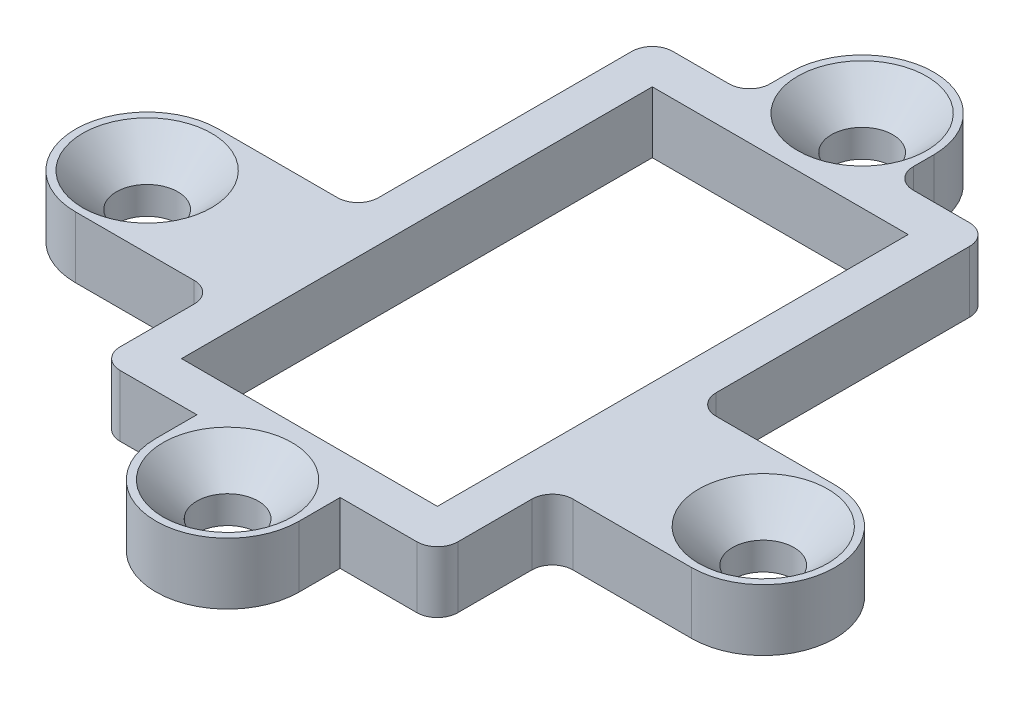
from build123d import *

# Parameters (mm, degrees)
SKETCH1_R                                      = 3.5
SKETCH1_W                                      = 16.5
SKETCH1_H                                      = 27
SKETCH1_W_2                                    = 12.5
SKETCH1_H_2                                    = 23
BOSS_EXTRUDE1_DEPTH                            = 3
FILLET1_R                                      = 1
CSK_FOR_M3_FLAT_HEAD_MACHINE_SCREW2_AT_2_COUNT = 2
CSK_FOR_M3_FLAT_HEAD_MACHINE_SCREW2_AT_2_PITCH = 30.1
CSK_FOR_M3_FLAT_HEAD_MACHINE_SCREW2_AT_3_COUNT = 2
CSK_FOR_M3_FLAT_HEAD_MACHINE_SCREW2_AT_3_PITCH = 18.712479793
CSK_FOR_M3_FLAT_HEAD_MACHINE_SCREW2_AT_4_COUNT = 2
CSK_FOR_M3_FLAT_HEAD_MACHINE_SCREW2_AT_4_PITCH = 24.934251543


with BuildPart() as part:
    # Sketch1 → Boss-Extrude1 (new body)
    with BuildSketch(Plane(origin=(0, 0, 0), x_dir=(1, 0, 0), z_dir=(0, 1, 0))):
        with BuildLine():
            ThreePointArc((-11.55, 0), (-12.575126266, 2.474873734), (-15.05, 3.5))
            ThreePointArc((-15.05, 3.5), (-18.55, 0), (-15.05, -3.5))
            ThreePointArc((-15.05, -3.5), (-12.575126266, -2.474873734), (-11.55, 0))
        make_face()
        with BuildLine():
            Line((-8.25, -3.5), (-8.25, 3.5))
            Line((-8.25, 3.5), (-15.05, 3.5))
            ThreePointArc((-15.05, 3.5), (-12.575126266, 2.474873734), (-11.55, 0))
            ThreePointArc((-11.55, 0), (-12.575126266, -2.474873734), (-15.05, -3.5))
            Line((-15.05, -3.5), (-8.25, -3.5))
        make_face()
        with Locations((0, -11.12)):
            Circle(SKETCH1_R)
        with Locations((0, 19.88)):
            Circle(SKETCH1_R)
        with Locations((0, 4.38)):
            Rectangle(SKETCH1_W, SKETCH1_H)
        with Locations((0, 4.38)):
            Rectangle(SKETCH1_W_2, SKETCH1_H_2, mode=Mode.SUBTRACT)
        with BuildLine():
            Line((-2.872281323, -9.12), (-3.5, -9.12))
            Line((-3.5, -9.12), (-3.5, -11.12))
            ThreePointArc((-3.5, -11.12), (-3.339385021, -10.071902827), (-2.872281323, -9.12))
        make_face()
        with BuildLine():
            ThreePointArc((2.872281323, -9.12), (0, -7.62), (-2.872281323, -9.12))
            Line((-2.872281323, -9.12), (2.872281323, -9.12))
        make_face()
        with BuildLine():
            Line((2.872281323, -9.12), (-2.872281323, -9.12))
            ThreePointArc((-2.872281323, -9.12), (-3.339385021, -10.071902827), (-3.5, -11.12))
            ThreePointArc((-3.5, -11.12), (0, -14.62), (3.5, -11.12))
            ThreePointArc((3.5, -11.12), (3.339385021, -10.071902827), (2.872281323, -9.12))
        make_face()
        with BuildLine():
            Line((3.5, -9.12), (2.872281323, -9.12))
            ThreePointArc((2.872281323, -9.12), (3.339385021, -10.071902827), (3.5, -11.12))
            Line((3.5, -11.12), (3.5, -9.12))
        make_face()
        with BuildLine():
            ThreePointArc((3.5, 19.88), (3.339385021, 18.831902827), (2.872281323, 17.88))
            Line((2.872281323, 17.88), (3.5, 17.88))
            Line((3.5, 17.88), (3.5, 19.88))
        make_face()
        with BuildLine():
            Line((2.872281323, 17.88), (-2.872281323, 17.88))
            ThreePointArc((-2.872281323, 17.88), (0, 16.38), (2.872281323, 17.88))
        make_face()
        with BuildLine():
            Line((-3.5, 19.88), (-3.5, 17.88))
            Line((-3.5, 17.88), (-2.872281323, 17.88))
            ThreePointArc((-2.872281323, 17.88), (-3.339385021, 18.831902827), (-3.5, 19.88))
        make_face()
        with BuildLine():
            ThreePointArc((-3.5, 19.88), (-3.339385021, 18.831902827), (-2.872281323, 17.88))
            Line((-2.872281323, 17.88), (2.872281323, 17.88))
            ThreePointArc((2.872281323, 17.88), (3.339385021, 18.831902827), (3.5, 19.88))
            ThreePointArc((3.5, 19.88), (0, 23.38), (-3.5, 19.88))
        make_face()
        with BuildLine():
            Line((15.05, 3.5), (8.25, 3.5))
            Line((8.25, 3.5), (8.25, -3.5))
            Line((8.25, -3.5), (15.05, -3.5))
            ThreePointArc((15.05, -3.5), (11.55, 0), (15.05, 3.5))
        make_face()
        with BuildLine():
            ThreePointArc((18.55, 0), (17.524873734, 2.474873734), (15.05, 3.5))
            ThreePointArc((15.05, 3.5), (11.55, 0), (15.05, -3.5))
            ThreePointArc((15.05, -3.5), (17.524873734, -2.474873734), (18.55, 0))
        make_face()
    extrude(amount=BOSS_EXTRUDE1_DEPTH)

    # Fillet1
    fillet1_edges = [part.edges().sort_by_distance(p)[0] for p in [
        (3.5, 1.5, -17.88),
        (8.25, 1.5, -17.88),
        (8.25, 1.5, -3.5),
        (8.25, 1.5, 3.5),
        (8.25, 1.5, 9.12),
        (-8.25, 1.5, 9.12),
        (-8.25, 1.5, 3.5),
        (-8.25, 1.5, -3.5),
        (-8.25, 1.5, -17.88),
        (-3.5, 1.5, -17.88),
    ]]
    fillet(fillet1_edges, radius=FILLET1_R)

    # Sketch2 → CSK for M3 Flat Head Machine Screw2 (revolve, cut)
    with BuildSketch(Plane(origin=(15.05, 3, 0), x_dir=(0, 0, 1), z_dir=(1, 0, 0))):
        Polygon((0, 0), (0, 3), (1.5, 3), (1.5, 1.65), (3.15, 0), align=None)
    csk_for_m3_flat_head_machine_screw2 = revolve(axis=Axis((15.05, 9.35, 0), (0, -1, 0)), mode=Mode.SUBTRACT)

    # CSK for M3 Flat Head Machine Screw2 at 2: CSK for M3 Flat Head Machine Screw2 ×2
    with Locations(*[(-i * CSK_FOR_M3_FLAT_HEAD_MACHINE_SCREW2_AT_2_PITCH, 0, 0) for i in range(1, CSK_FOR_M3_FLAT_HEAD_MACHINE_SCREW2_AT_2_COUNT)]):
        add(csk_for_m3_flat_head_machine_screw2, mode=Mode.SUBTRACT)

    # CSK for M3 Flat Head Machine Screw2 at 3: CSK for M3 Flat Head Machine Screw2 ×2
    with Locations(*[Vector(-0.804276086, 0, 0.594255819) * (i * CSK_FOR_M3_FLAT_HEAD_MACHINE_SCREW2_AT_3_PITCH) for i in range(1, CSK_FOR_M3_FLAT_HEAD_MACHINE_SCREW2_AT_3_COUNT)]):
        add(csk_for_m3_flat_head_machine_screw2, mode=Mode.SUBTRACT)

    # CSK for M3 Flat Head Machine Screw2 at 4: CSK for M3 Flat Head Machine Screw2 ×2
    with Locations(*[Vector(-0.603587398, 0, -0.797296841) * (i * CSK_FOR_M3_FLAT_HEAD_MACHINE_SCREW2_AT_4_PITCH) for i in range(1, CSK_FOR_M3_FLAT_HEAD_MACHINE_SCREW2_AT_4_COUNT)]):
        add(csk_for_m3_flat_head_machine_screw2, mode=Mode.SUBTRACT)


solid = part.part
